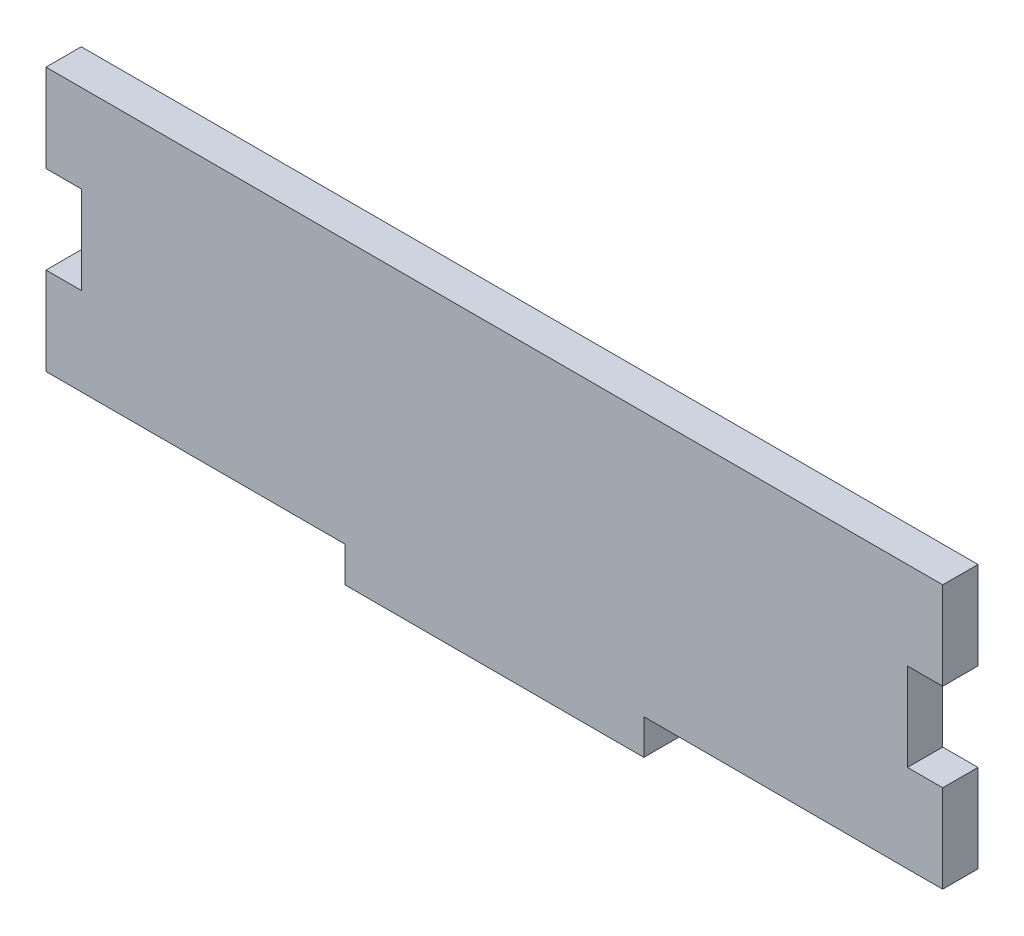
from build123d import *

# Parameters (mm, degrees)
BOSS_EXTRUDE1_DEPTH = 2.9972


with BuildPart() as part:
    # Sketch1 → Boss-Extrude1 (new body)
    with BuildSketch(Plane.XY):
        Polygon((-15.355763029, 18.852859277), (-15.355763029, 26.320459277), (60.844236971, 26.320459277), (60.844236971, 18.852859277), (57.847036971, 18.852859277), (57.847036971, 11.385259277), (60.844236971, 11.385259277), (60.844236971, 3.917659277), (35.444236971, 3.917659277), (35.444236971, 0.920459277), (10.044236971, 0.920459277), (10.044236971, 3.917659277), (-15.355763029, 3.917659277), (-15.355763029, 11.385259277), (-12.358563029, 11.385259277), (-12.358563029, 18.852859277), align=None)
    extrude(amount=BOSS_EXTRUDE1_DEPTH)


solid = part.part
